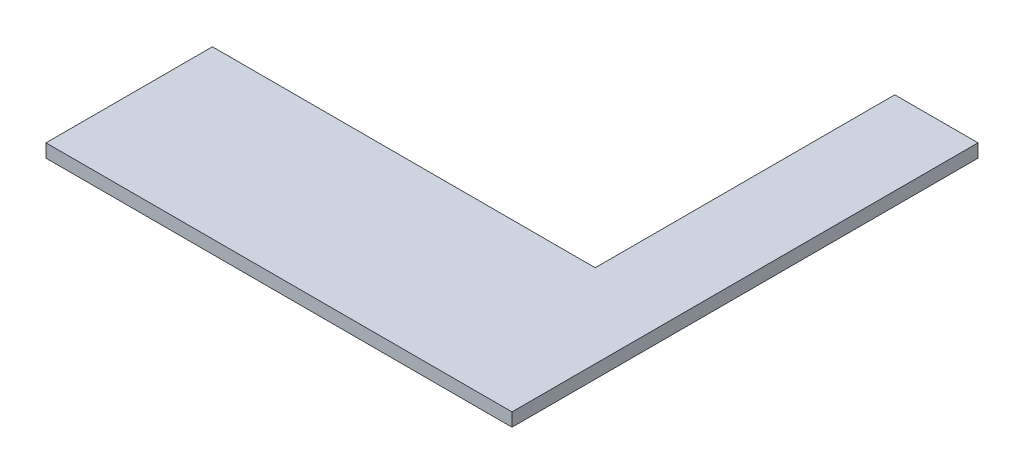
from build123d import *

# Parameters (mm, degrees)
BOSS_EXTRUDE1_DEPTH = 4


with BuildPart() as part:
    # Sketch1 → Boss-Extrude1 (new body)
    with BuildSketch(Plane(origin=(0, 0, 0), x_dir=(1, 0, 0), z_dir=(0, 1, 0))):
        Polygon((0, 0), (-140, 0), (-140, 50), (-25, 50), (-25, 140), (0, 140), align=None)
    extrude(amount=BOSS_EXTRUDE1_DEPTH)


solid = part.part
